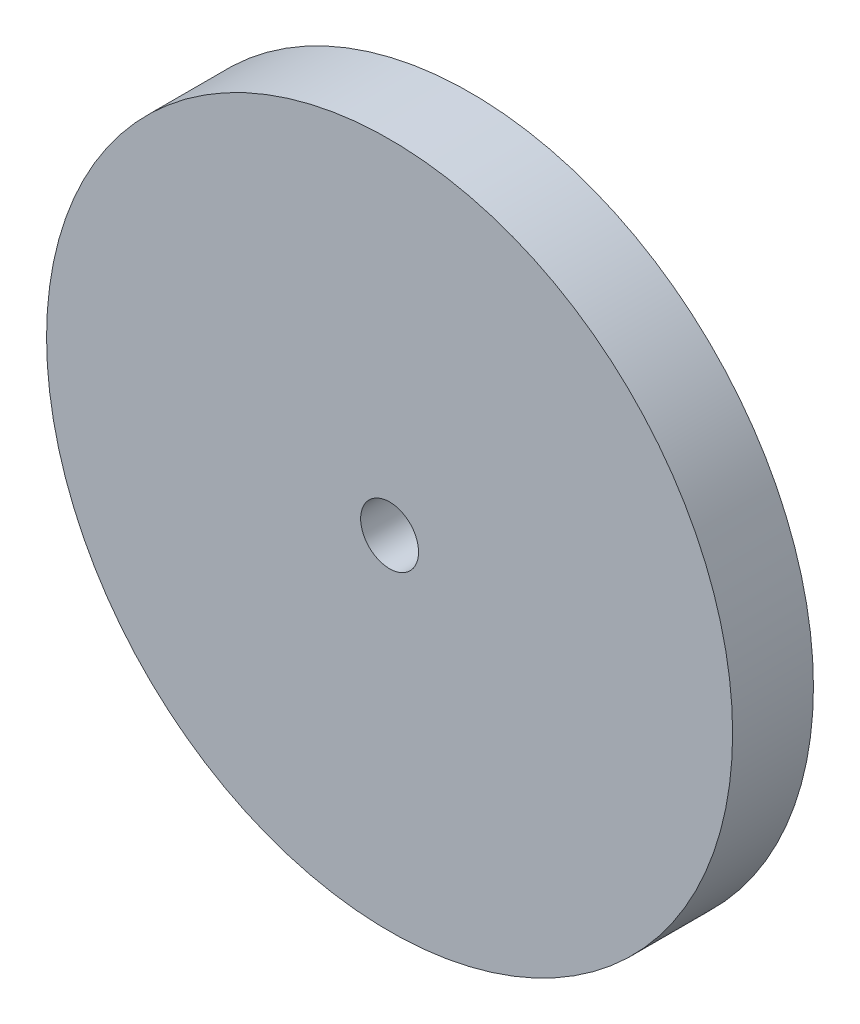
from build123d import *

# Parameters (mm, degrees)
SKETCH1_R           = 32.3469
BOSS_EXTRUDE1_DEPTH = 3.81
SKETCH2_R           = 2.7305
CUT_EXTRUDE1_DEPTH  = 7.62


with BuildPart() as part:
    # Sketch1 → Boss-Extrude1 (new body, symmetric)
    with BuildSketch(Plane.XY):
        Circle(SKETCH1_R)
    extrude(amount=BOSS_EXTRUDE1_DEPTH, both=True)

    # Sketch2 → Cut-Extrude1 (cut)
    with BuildSketch(Plane.XY.offset(3.81)):
        Circle(SKETCH2_R)
    extrude(amount=-CUT_EXTRUDE1_DEPTH, mode=Mode.SUBTRACT)


solid = part.part
